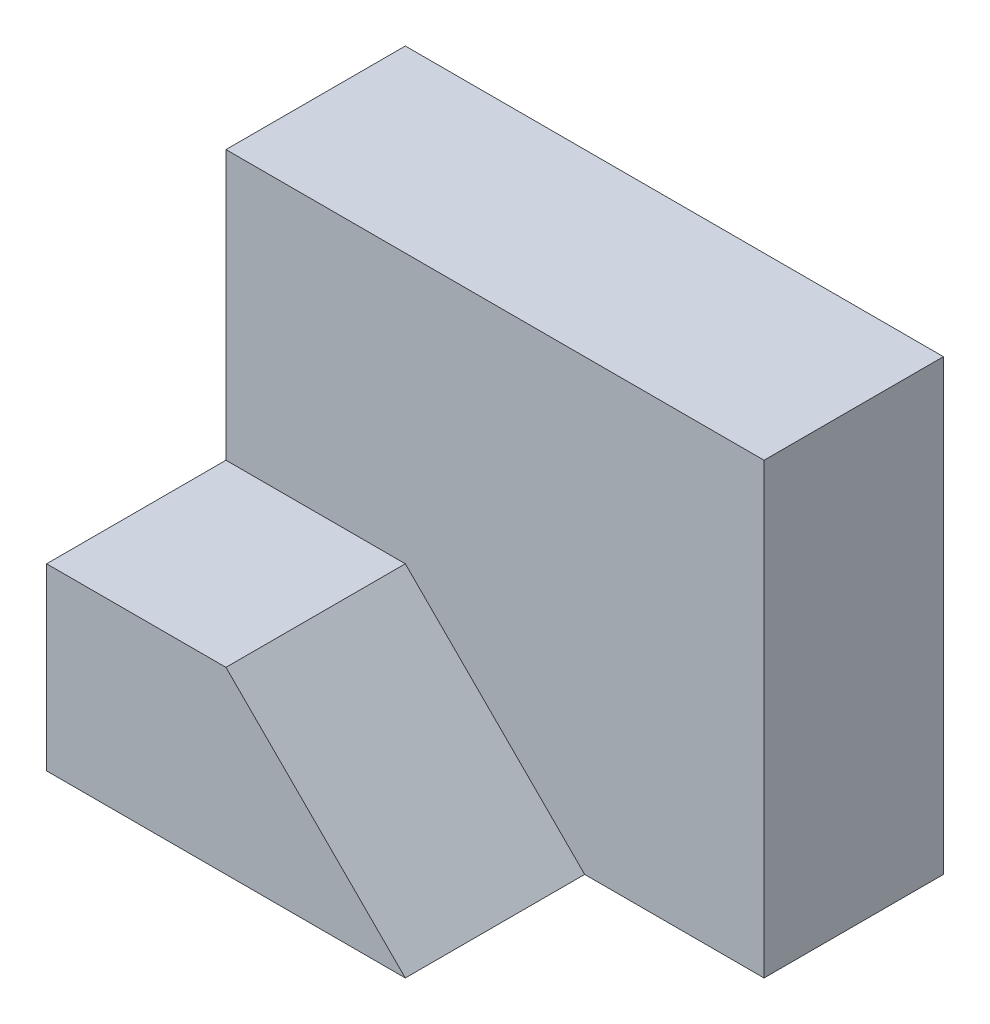
from build123d import *

# Parameters (mm, degrees)
SKETCH1_W           = 6
SKETCH1_H           = 5
BOSS_EXTRUDE1_DEPTH = 2
BOSS_EXTRUDE2_DEPTH = 2


with BuildPart() as part:
    # Sketch1 → Boss-Extrude1 (new body)
    with BuildSketch(Plane.XY):
        with Locations((3, 2.5)):
            Rectangle(SKETCH1_W, SKETCH1_H)
    extrude(amount=BOSS_EXTRUDE1_DEPTH)

    # Sketch2 → Boss-Extrude2 (add)
    with BuildSketch(Plane.XY.offset(2)):
        Polygon((0, 0), (0, 2), (2, 2), (4, 0), align=None)
    extrude(amount=BOSS_EXTRUDE2_DEPTH)


solid = part.part
